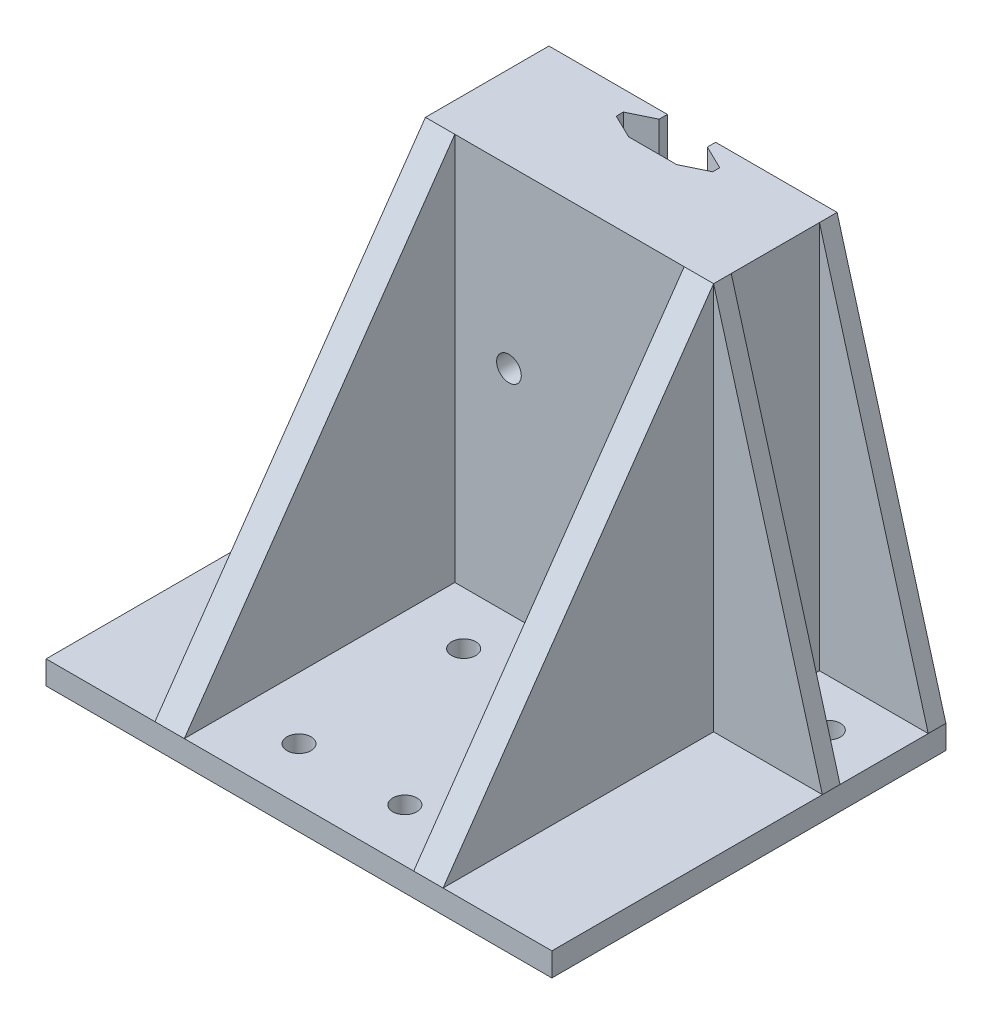
from build123d import *

# Parameters (mm, degrees)
EXTRUDE_1_DEPTH     = 17
SKETCH_5_R          = 3
CUT_EXTRUDE_3_DEPTH = 49
SKETCH_6_W          = 49
SKETCH_6_H          = 4
EXTRUDE_3_DEPTH     = 50
SKETCH_7_W          = 67
SKETCH_7_H          = 4
EXTRUDE_4_DEPTH     = 18.5
SKETCH_8_W          = 67
SKETCH_8_H          = 4
EXTRUDE_5_DEPTH     = 18.5
SKETCH_14_W         = 49
SKETCH_14_H         = 4
EXTRUDE_13_DEPTH    = 66
SKETCH_23_W         = 49
SKETCH_23_H         = 19.9
EXTRUDE_18_DEPTH    = 17
CUT_EXTRUDE_4_REACH = 6
SKETCH_13_R         = 2.05
EXTRUDE_14_DEPTH    = 5
EXTRUDE_15_DEPTH    = 5
CUT_EXTRUDE_5_REACH = 23
SKETCH_18_R         = 2.1
SKETCH_21_W         = 34.5
SKETCH_21_H         = 0.7
CUT_EXTRUDE_6_DEPTH = 4.6
EXTRUDE_19_DEPTH    = 3
EXTRUDE_20_DEPTH    = 3
EXTRUDE_21_REACH    = 42
SKETCH_29_W         = 4.15
SKETCH_29_H         = 17
SKETCH_29_W_2       = 4.65
SKETCH_3_W          = 2
SKETCH_3_H          = 12.5
CUT_EXTRUDE_7_DEPTH = 17
CUT_EXTRUDE_8_DEPTH = 20


with BuildPart() as part:
    # Эскиз1 → Бобышка-Вытянуть1 (new body)
    with BuildSketch(Plane.XY):
        Polygon((-13.125, 2.698768931), (-15.5, 2.698768931), (-15.5, 4.138768931), (-12.84, 6.798768931), (-7.36, 6.798768931), (-4.7, 4.138768931), (-4.7, 2.698768931), (-7.075, 2.698768931), (-7.075, 0.698768931), (6.875, 0.698768931), (6.875, 2.698768931), (4.5, 2.698768931), (4.5, 4.138768931), (7.16, 6.798768931), (12.64, 6.798768931), (15.3, 4.138768931), (15.3, 2.698768931), (12.925, 2.698768931), (12.925, 0.698768931), (24.65, 0.698768931), (24.65, -29.301231069), (15.25, -29.301231069), (15.25, -4.901231069), (-19.45, -4.901231069), (-19.45, -29.301231069), (-24.35, -29.301231069), (-24.35, 0.698768931), (-13.125, 0.698768931), align=None)
    extrude(amount=EXTRUDE_1_DEPTH)

    # Эскиз5 → Вырез-Вытянуть3 (cut)
    with BuildSketch(Plane.ZY.offset(24.35)):
        with Locations((9, -17.301231069)):
            Circle(SKETCH_5_R)
    extrude(amount=-CUT_EXTRUDE_3_DEPTH, mode=Mode.SUBTRACT)

    # Эскиз6 → Бобышка-Вытянуть3 (add)
    with BuildSketch(Plane.XY.offset(17)):
        with Locations((0.15, -27.301231069)):
            Rectangle(SKETCH_6_W, SKETCH_6_H)
    extrude(amount=EXTRUDE_3_DEPTH)

    # Эскиз7 → Бобышка-Вытянуть4 (add)
    with BuildSketch(Plane.ZY.offset(24.35)):
        with Locations((33.5, -27.301231069)):
            Rectangle(SKETCH_7_W, SKETCH_7_H)
    extrude(amount=EXTRUDE_4_DEPTH)

    # Эскиз8 → Бобышка-Вытянуть5 (add)
    with BuildSketch(Plane(origin=(24.65, 0, 0), x_dir=(0, 0, -1), z_dir=(1, 0, 0))):
        with Locations((-33.5, -27.301231069)):
            Rectangle(SKETCH_8_W, SKETCH_8_H)
    extrude(amount=EXTRUDE_5_DEPTH)

    # Эскиз14 → Бобышка-Вытянуть13 (add)
    with BuildSketch(Plane(origin=(0, -25.301231069, 0), x_dir=(1, 0, 0), z_dir=(0, 1, 0))):
        with Locations((0.15, -19)):
            Rectangle(SKETCH_14_W, SKETCH_14_H)
    extrude(amount=EXTRUDE_13_DEPTH)

    # Эскиз23 → Бобышка-Вытянуть18 (add)
    with BuildSketch(Plane(origin=(0, 0, 17), x_dir=(-1, 0, 0), z_dir=(0, 0, -1))):
        with Locations((-0.15, 30.748768931)):
            Rectangle(SKETCH_23_W, SKETCH_23_H)
    extrude(amount=EXTRUDE_18_DEPTH)

    # Эскиз13 → Вырез-Вытянуть4 (cut, up to next)
    with BuildSketch(Plane(origin=(0, -25.301231069, 0), x_dir=(1, 0, 0), z_dir=(0, 1, 0)), mode=Mode.PRIVATE) as cut_extrude_4_sk1:
        with Locations((-8.85, -58)):
            Circle(SKETCH_13_R)
    cut_extrude_4_tool1 = extrude(cut_extrude_4_sk1.sketch, amount=-CUT_EXTRUDE_4_REACH, mode=Mode.PRIVATE) & part.part
    add(cut_extrude_4_tool1.solids().sort_by_distance((-8.85, -25.301231, 58))[0], mode=Mode.SUBTRACT)
    # Эскиз13 → Вырез-Вытянуть4 (cut, up to next)
    with BuildSketch(Plane(origin=(0, -25.301231069, 0), x_dir=(1, 0, 0), z_dir=(0, 1, 0)), mode=Mode.PRIVATE) as cut_extrude_4_sk2:
        with Locations((9.15, -58)):
            Circle(SKETCH_13_R)
    cut_extrude_4_tool2 = extrude(cut_extrude_4_sk2.sketch, amount=-CUT_EXTRUDE_4_REACH, mode=Mode.PRIVATE) & part.part
    add(cut_extrude_4_tool2.solids().sort_by_distance((9.15, -25.301231, 58))[0], mode=Mode.SUBTRACT)
    # Эскиз13 → Вырез-Вытянуть4 (cut, up to next)
    with BuildSketch(Plane(origin=(0, -25.301231069, 0), x_dir=(1, 0, 0), z_dir=(0, 1, 0)), mode=Mode.PRIVATE) as cut_extrude_4_sk3:
        with Locations((-33.85, -11)):
            Circle(SKETCH_13_R)
    cut_extrude_4_tool3 = extrude(cut_extrude_4_sk3.sketch, amount=-CUT_EXTRUDE_4_REACH, mode=Mode.PRIVATE) & part.part
    add(cut_extrude_4_tool3.solids().sort_by_distance((-33.85, -25.301231, 11))[0], mode=Mode.SUBTRACT)
    # Эскиз13 → Вырез-Вытянуть4 (cut, up to next)
    with BuildSketch(Plane(origin=(0, -25.301231069, 0), x_dir=(1, 0, 0), z_dir=(0, 1, 0)), mode=Mode.PRIVATE) as cut_extrude_4_sk4:
        with Locations((34.15, -11)):
            Circle(SKETCH_13_R)
    cut_extrude_4_tool4 = extrude(cut_extrude_4_sk4.sketch, amount=-CUT_EXTRUDE_4_REACH, mode=Mode.PRIVATE) & part.part
    add(cut_extrude_4_tool4.solids().sort_by_distance((34.15, -25.301231, 11))[0], mode=Mode.SUBTRACT)
    # Эскиз13 → Вырез-Вытянуть4 (cut, up to next)
    with BuildSketch(Plane(origin=(0, -25.301231069, 0), x_dir=(1, 0, 0), z_dir=(0, 1, 0)), mode=Mode.PRIVATE) as cut_extrude_4_sk5:
        with Locations((-8.85, -30)):
            Circle(SKETCH_13_R)
    cut_extrude_4_tool5 = extrude(cut_extrude_4_sk5.sketch, amount=-CUT_EXTRUDE_4_REACH, mode=Mode.PRIVATE) & part.part
    add(cut_extrude_4_tool5.solids().sort_by_distance((-8.85, -25.301231, 30))[0], mode=Mode.SUBTRACT)
    # Эскиз13 → Вырез-Вытянуть4 (cut, up to next)
    with BuildSketch(Plane(origin=(0, -25.301231069, 0), x_dir=(1, 0, 0), z_dir=(0, 1, 0)), mode=Mode.PRIVATE) as cut_extrude_4_sk6:
        with Locations((9.15, -30)):
            Circle(SKETCH_13_R)
    cut_extrude_4_tool6 = extrude(cut_extrude_4_sk6.sketch, amount=-CUT_EXTRUDE_4_REACH, mode=Mode.PRIVATE) & part.part
    add(cut_extrude_4_tool6.solids().sort_by_distance((9.15, -25.301231, 30))[0], mode=Mode.SUBTRACT)

    # Эскиз16 → Бобышка-Вытянуть14 (add)
    with BuildSketch(Plane.ZY.offset(24.35)):
        Polygon((21, -25.301231069), (21, 40.698768931), (67, -25.301231069), align=None)
    extrude(amount=-EXTRUDE_14_DEPTH)

    # Эскиз17 → Бобышка-Вытянуть15 (add)
    with BuildSketch(Plane(origin=(24.65, 0, 0), x_dir=(0, 0, -1), z_dir=(1, 0, 0))):
        Polygon((-67, -25.301231069), (-21, 40.698768931), (-21, -25.301231069), align=None)
    extrude(amount=-EXTRUDE_15_DEPTH)

    # Эскиз18 → Вырез-Вытянуть5 (cut, up to next)
    with BuildSketch(Plane.XY.offset(21), mode=Mode.PRIVATE) as cut_extrude_5_sk1:
        with Locations((9.85, 10.798768931)):
            Circle(SKETCH_18_R)
    cut_extrude_5_tool1 = extrude(cut_extrude_5_sk1.sketch, amount=-CUT_EXTRUDE_5_REACH, mode=Mode.PRIVATE) & part.part
    add(cut_extrude_5_tool1.solids().sort_by_distance((9.85, 10.798769, 21))[0], mode=Mode.SUBTRACT)
    # Эскиз18 → Вырез-Вытянуть5 (cut, up to next)
    with BuildSketch(Plane.XY.offset(21), mode=Mode.PRIVATE) as cut_extrude_5_sk2:
        with Locations((-10.15, 10.798768931)):
            Circle(SKETCH_18_R)
    cut_extrude_5_tool2 = extrude(cut_extrude_5_sk2.sketch, amount=-CUT_EXTRUDE_5_REACH, mode=Mode.PRIVATE) & part.part
    add(cut_extrude_5_tool2.solids().sort_by_distance((-10.15, 10.798769, 21))[0], mode=Mode.SUBTRACT)

    # Эскиз21 → Вырез-Вытянуть6 (cut)
    with BuildSketch(Plane(origin=(0, 0, 0), x_dir=(-1, 0, 0), z_dir=(0, 0, -1))):
        with Locations((2, -4.551231069)):
            Rectangle(SKETCH_21_W, SKETCH_21_H)
    extrude(amount=-CUT_EXTRUDE_6_DEPTH, mode=Mode.SUBTRACT)

    # Эскиз25 → Бобышка-Вытянуть19 (add)
    with BuildSketch(Plane(origin=(0, 0, 0), x_dir=(-1, 0, 0), z_dir=(0, 0, -1))):
        Polygon((-24.65, 40.698768931), (-24.65, -25.301231069), (-43.15, -25.301231069), align=None)
        Polygon((42.85, -25.301231069), (24.35, -25.301231069), (24.35, 40.698768931), align=None)
    extrude(amount=-EXTRUDE_19_DEPTH)

    # Эскиз28 → Бобышка-Вытянуть20 (add)
    with BuildSketch(Plane.XY.offset(21)):
        Polygon((43.15, -25.301231069), (24.65, -25.301231069), (24.65, 40.698768931), align=None)
        Polygon((-24.35, -25.301231069), (-42.85, -25.301231069), (-24.35, 40.698768931), align=None)
    extrude(amount=-EXTRUDE_20_DEPTH)

    # Эскиз29 → Бобышка-Вытянуть21 (add, up to next)
    with BuildSketch(Plane(origin=(0, 0.698768931, 0), x_dir=(1, 0, 0), z_dir=(0, 1, 0)), mode=Mode.PRIVATE) as extrude_21_sk1:
        with Locations((-22.275, -8.5)):
            Rectangle(SKETCH_29_W, SKETCH_29_H)
    extrude_21_tool1 = extrude(extrude_21_sk1.sketch, amount=EXTRUDE_21_REACH, mode=Mode.PRIVATE) - part.part
    add(extrude_21_tool1.solids().sort_by_distance((-22.275, 0.698769, 8.5))[0])
    # Эскиз29 → Бобышка-Вытянуть21 (add, up to next)
    with BuildSketch(Plane(origin=(0, 0.698768931, 0), x_dir=(1, 0, 0), z_dir=(0, 1, 0)), mode=Mode.PRIVATE) as extrude_21_sk2:
        with Locations((22.325, -8.5)):
            Rectangle(SKETCH_29_W_2, SKETCH_29_H)
    extrude_21_tool2 = extrude(extrude_21_sk2.sketch, amount=EXTRUDE_21_REACH, mode=Mode.PRIVATE) - part.part
    add(extrude_21_tool2.solids().sort_by_distance((22.325, 0.698769, 8.5))[0])

    # Эскиз3 → Вырез-Вытянуть7 (cut)
    with BuildSketch(Plane(origin=(0, 0, 0), x_dir=(-1, 0, 0), z_dir=(0, 0, -1))):
        with Locations((20.25, -17.051231069)):
            Rectangle(SKETCH_3_W, SKETCH_3_H)
    extrude(amount=-CUT_EXTRUDE_7_DEPTH, mode=Mode.SUBTRACT)

    # Эскиз30 → Вырез-Вытянуть8 (cut)
    with BuildSketch(Plane(origin=(0, 40.698768931, 0), x_dir=(1, 0, 0), z_dir=(0, 1, 0))):
        Polygon((-4.2, 0), (4, 0), (4, -1.4), (8.1, -3.4), (8.1, -4.6), (4, -6.6), (-4.2, -6.6), (-8.3, -4.6), (-8.3, -3.4), (-4.2, -1.4), align=None)
    extrude(amount=-CUT_EXTRUDE_8_DEPTH, mode=Mode.SUBTRACT)


solid = part.part
